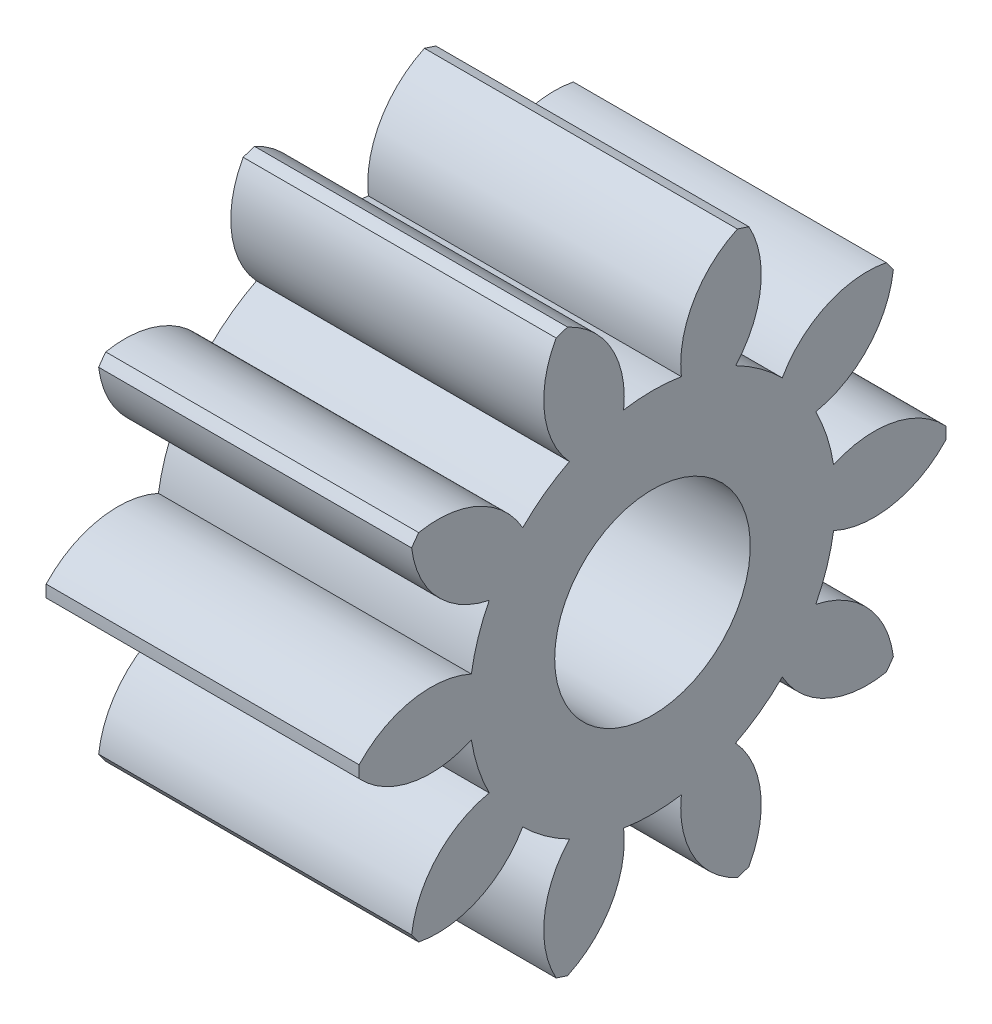
from build123d import *

# Parameters (mm, degrees)
BASPROSKE_W     = 8
BASPROSKE_H     = 7.5
TOOTHCUT_DEPTH  = 14.285330256
TEETHCUTS_COUNT = 10
TEETHCUTS_ANGLE = 324
BORSKE_R        = 2.5
BORE_DEPTH      = 50.0000508


with BuildPart() as part:
    # BasProSke → Base-Revolve (revolve)
    with BuildSketch(Plane(origin=(0, 0, 0), x_dir=(1, 0, 0), z_dir=(0, 1, 0)), mode=Mode.PRIVATE) as base_revolve_sk:
        with Locations((4, 3.75)):
            Rectangle(BASPROSKE_W, BASPROSKE_H)
    revolve(base_revolve_sk.sketch.rotate(Axis((-10, 0, 0), (1, 0, 0)), 180), axis=Axis((-10, 0, 0), (1, 0, 0)))

    # TooCutSke → ToothCut (cut, through all)
    with BuildSketch(Plane(origin=(0, 0, 0), x_dir=(0, 0, -1), z_dir=(1, 0, 0))):
        with BuildLine():
            ThreePointArc((0.737676151, 4.628079099), (0, 4.6865), (-0.737676151, 4.628079099))
            ThreePointArc((-0.737676151, 4.628079099), (-1.051542781, 6.151798382), (-2.205760267, 7.194877817))
            ThreePointArc((-2.205760267, 7.194877817), (0, 7.5254), (2.205760267, 7.194877817))
            ThreePointArc((2.205760267, 7.194877817), (1.051542781, 6.151798382), (0.737676151, 4.628079099))
        make_face()
    toothcut = extrude(amount=TOOTHCUT_DEPTH, mode=Mode.SUBTRACT)

    # TeethCuts: ToothCut ×10 about axis
    teethcuts_axis = Axis((-10, 0, 0), (1, 0, 0))
    for i in range(1, TEETHCUTS_COUNT):
        add(toothcut.rotate(teethcuts_axis, i * TEETHCUTS_ANGLE / (TEETHCUTS_COUNT - 1)), mode=Mode.SUBTRACT)

    # BorSke → Bore (cut, symmetric)
    with BuildSketch(Plane(origin=(0, 0, 0), x_dir=(0, 0, -1), z_dir=(1, 0, 0))):
        with Locations(Location((0, 0, 0), (0, 0, 180))):
            Circle(BORSKE_R)
    extrude(amount=BORE_DEPTH, both=True, mode=Mode.SUBTRACT)


solid = part.part
